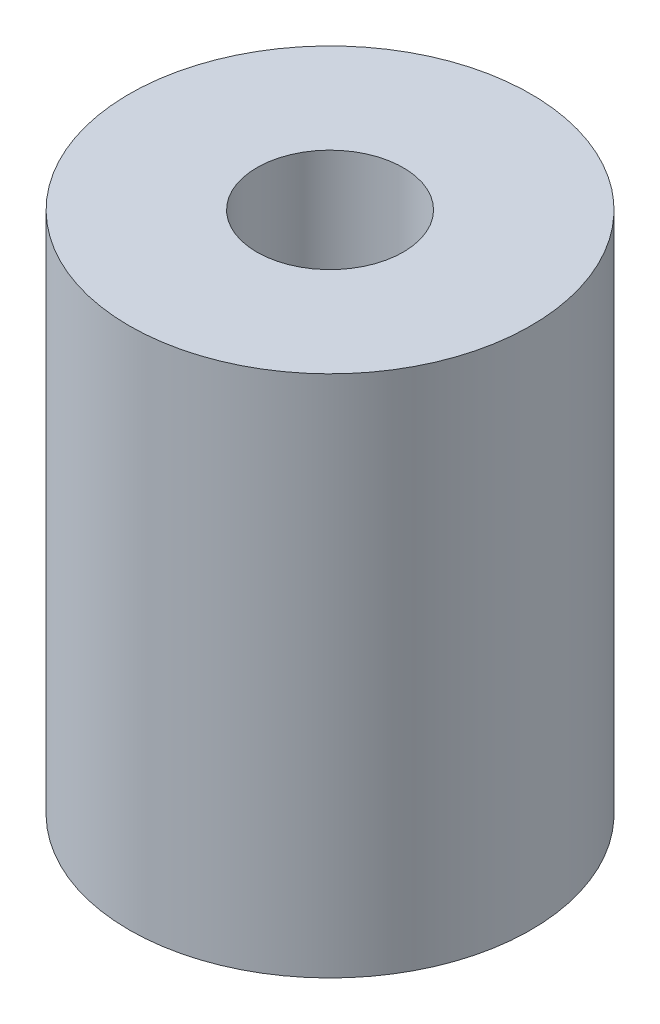
from build123d import *

# Parameters (mm, degrees)
SKETCH1_R           = 11.1125
SKETCH1_R_2         = 4.0513
BOSS_EXTRUDE1_DEPTH = 28.956


with BuildPart() as part:
    # Sketch1 → Boss-Extrude1 (new body)
    with BuildSketch(Plane(origin=(0, 0, 0), x_dir=(1, 0, 0), z_dir=(0, 1, 0))):
        Circle(SKETCH1_R)
        Circle(SKETCH1_R_2, mode=Mode.SUBTRACT)
    extrude(amount=BOSS_EXTRUDE1_DEPTH)


solid = part.part
